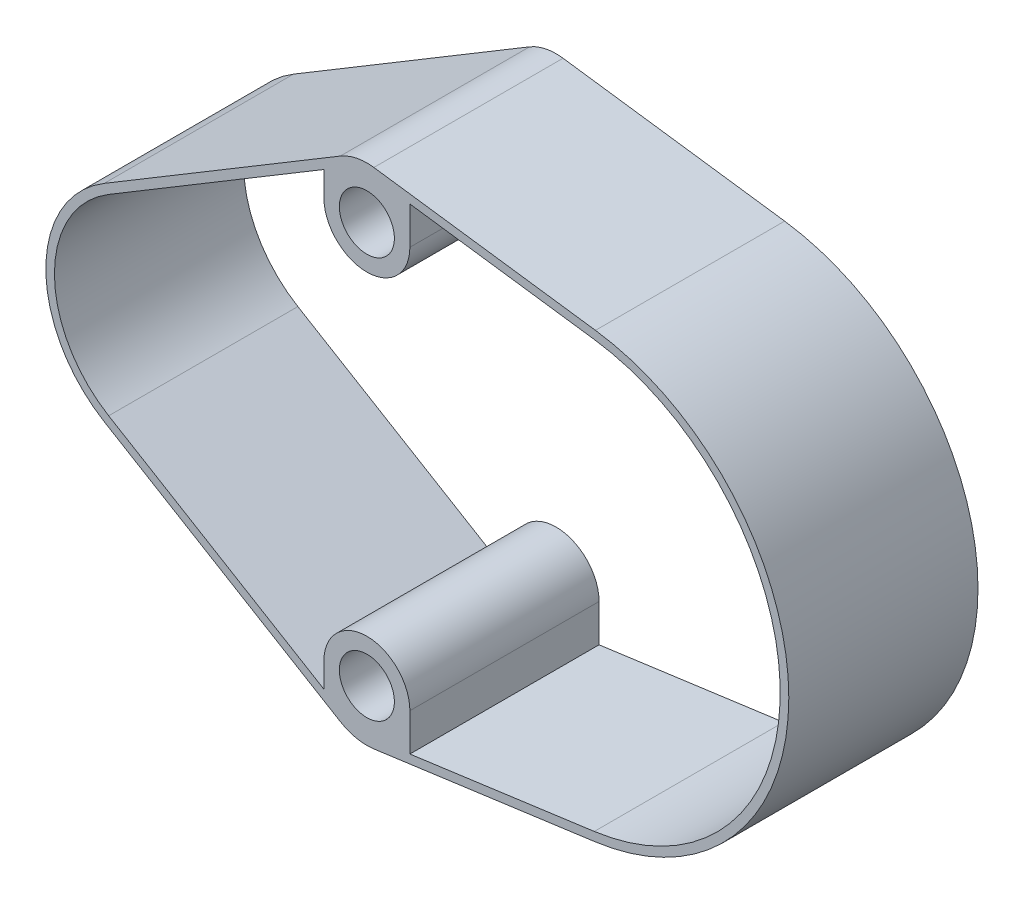
from build123d import *

# Parameters (mm, degrees)
SKETCH1_R           = 3
SKETCH1_R_2         = 4.5
SKETCH1_R_3         = 1.6
BOSS_EXTRUDE3_DEPTH = 1.6
SKETCH2_R           = 1.6
SKETCH2_R_2         = 3
SKETCH2_R_3         = 4.5
BOSS_EXTRUDE4_DEPTH = 1.5
SKETCH3_R           = 63.206562555
CUT_EXTRUDE1_DEPTH  = 1.6
SKETCH4_R           = 3
SKETCH4_R_2         = 1.6
BOSS_EXTRUDE5_DEPTH = 1.5
SKETCH5_R           = 1.6
BOSS_EXTRUDE6_DEPTH = 11
SKETCH6_R           = 49.514430464
CUT_EXTRUDE2_DEPTH  = 1.5


with BuildPart() as part:
    # Sketch1 → Boss-Extrude3 (new body)
    with BuildSketch(Plane.XY):
        with BuildLine():
            Line((12.073070054, 14.639688463), (24.958502044, 12.880515151))
            ThreePointArc((24.958502044, 12.880515151), (36.2, 0), (24.958502044, -12.880515151))
            Line((24.958502044, -12.880515151), (12.073070054, -14.639688463))
            ThreePointArc((12.073070054, -14.639688463), (11.870633815, -14.660360595), (11.66726189, -14.66726189))
            Line((11.66726189, -14.66726189), (0, -14.66726189))
            ThreePointArc((0, -14.66726189), (-0.888679088, -14.53261518), (-1.697586366, -14.140761542))
            Line((-1.697586366, -14.140761542), (-18.697586366, -2.473499652))
            ThreePointArc((-18.697586366, -2.473499652), (-19.891071988, -0.801063519), (-19.728500117, 1.247111507))
            Line((-19.728500117, 1.247111507), (-14.395762007, 12.914373397))
            ThreePointArc((-14.395762007, 12.914373397), (-13.288783625, 14.191279968), (-11.66726189, 14.66726189))
            Line((-11.66726189, 14.66726189), (11.66726189, 14.66726189))
            ThreePointArc((11.66726189, 14.66726189), (11.870633815, 14.660360595), (12.073070054, 14.639688463))
        make_face()
        Circle(SKETCH1_R, mode=Mode.SUBTRACT)
        with Locations((23.2, 0)):
            Circle(SKETCH1_R_2, mode=Mode.SUBTRACT)
        with Locations((8.6, 0)):
            Circle(SKETCH1_R, mode=Mode.SUBTRACT)
        with Locations((-17, 0)):
            Circle(SKETCH1_R_3, mode=Mode.SUBTRACT)
        with Locations((0, -11.66726189)):
            Circle(SKETCH1_R_3, mode=Mode.SUBTRACT)
        with Locations((11.66726189, -11.66726189)):
            Circle(SKETCH1_R_3, mode=Mode.SUBTRACT)
        with Locations((-11.66726189, 11.66726189)):
            Circle(SKETCH1_R_3, mode=Mode.SUBTRACT)
        with Locations((0, 11.66726189)):
            Circle(SKETCH1_R_3, mode=Mode.SUBTRACT)
        with Locations((11.66726189, 11.66726189)):
            Circle(SKETCH1_R_3, mode=Mode.SUBTRACT)
    extrude(amount=BOSS_EXTRUDE3_DEPTH)

    # Sketch2 → Boss-Extrude4 (add)
    with BuildSketch(Plane.XY.offset(1.6)):
        with BuildLine():
            Line((12.073070054, 14.639688463), (24.958502044, 12.880515151))
            ThreePointArc((24.958502044, 12.880515151), (36.2, 0), (24.958502044, -12.880515151))
            Line((24.958502044, -12.880515151), (12.073070054, -14.639688463))
            ThreePointArc((12.073070054, -14.639688463), (10.884137398, -14.56324463), (9.81871257, -14.030070687))
            Line((9.81871257, -14.030070687), (-3.080915533, -3.938014662))
            ThreePointArc((-3.080915533, -3.938014662), (-5, 0), (-3.080915533, 3.938014662))
            Line((-3.080915533, 3.938014662), (9.81871257, 14.030070687))
            ThreePointArc((9.81871257, 14.030070687), (10.884137398, 14.56324463), (12.073070054, 14.639688463))
        make_face()
        with Locations((11.66726189, 11.66726189)):
            Circle(SKETCH2_R, mode=Mode.SUBTRACT)
        Circle(SKETCH2_R_2, mode=Mode.SUBTRACT)
        with Locations((8.6, 0)):
            Circle(SKETCH2_R_2, mode=Mode.SUBTRACT)
        with Locations((23.2, 0)):
            Circle(SKETCH2_R_3, mode=Mode.SUBTRACT)
        with Locations((11.66726189, -11.66726189)):
            Circle(SKETCH2_R, mode=Mode.SUBTRACT)
    extrude(amount=BOSS_EXTRUDE4_DEPTH)

    # Sketch3 → Cut-Extrude1 (cut)
    with BuildSketch(Plane(origin=(0, 0, 0), x_dir=(-1, 0, 0), z_dir=(0, 0, -1))):
        Circle(SKETCH3_R)
    extrude(amount=-CUT_EXTRUDE1_DEPTH, mode=Mode.SUBTRACT)

    # Sketch4 → Boss-Extrude5 (add)
    with BuildSketch(Plane.XY.offset(3.1)):
        with BuildLine():
            Line((-3.602159399, 6.00203696), (10.12347929, 14.239563444))
            ThreePointArc((10.12347929, 14.239563444), (13.145208472, 14.277946455), (14.66726189, 11.66726189))
            Line((14.66726189, 11.66726189), (14.66726189, -11.66726189))
            ThreePointArc((14.66726189, -11.66726189), (13.145208472, -14.277946455), (10.12347929, -14.239563444))
            Line((10.12347929, -14.239563444), (-3.602159399, -6.00203696))
            ThreePointArc((-3.602159399, -6.00203696), (-7, 0), (-3.602159399, 6.00203696))
        make_face()
        Circle(SKETCH4_R, mode=Mode.SUBTRACT)
        with Locations((8.6, 0)):
            Circle(SKETCH4_R, mode=Mode.SUBTRACT)
        with Locations((11.66726189, 11.66726189)):
            Circle(SKETCH4_R_2, mode=Mode.SUBTRACT)
        with Locations((11.66726189, -11.66726189)):
            Circle(SKETCH4_R_2, mode=Mode.SUBTRACT)
    extrude(amount=-BOSS_EXTRUDE5_DEPTH)

    # Sketch5 → Boss-Extrude6 (add)
    with BuildSketch(Plane.XY.offset(3.1)):
        with BuildLine():
            Line((10.12347929, 14.239563444), (-3.602159399, 6.00203696))
            ThreePointArc((-3.602159399, 6.00203696), (-7, 0), (-3.602159399, -6.00203696))
            Line((-3.602159399, -6.00203696), (10.12347929, -14.239563444))
            ThreePointArc((10.12347929, -14.239563444), (11.064127193, -14.606007972), (12.073070054, -14.639688463))
            Line((12.073070054, -14.639688463), (24.958502044, -12.880515151))
            ThreePointArc((24.958502044, -12.880515151), (36.2, 0), (24.958502044, 12.880515151))
            Line((24.958502044, 12.880515151), (12.073070054, 14.639688463))
            ThreePointArc((12.073070054, 14.639688463), (11.064127193, 14.606007972), (10.12347929, 14.239563444))
        make_face()
        with Locations((11.66726189, -11.66726189)):
            Circle(SKETCH5_R, mode=Mode.SUBTRACT)
        with BuildLine():
            Line((-3.345341009, 5.573371264), (3.517564288, 9.692737701))
            Line((3.517564288, 9.692737701), (9.16726189, 13.083892566))
            Line((9.16726189, 13.083892566), (9.16726189, 11.66726189))
            ThreePointArc((9.16726189, 11.66726189), (11.66726189, 9.16726189), (14.16726189, 11.66726189))
            Line((14.16726189, 11.66726189), (14.16726189, 13.849142394))
            Line((14.16726189, 13.849142394), (18.333589211, 13.280337883))
            Line((18.333589211, 13.280337883), (24.89086735, 12.385110722))
            ThreePointArc((24.89086735, 12.385110722), (35.7, 0), (24.89086735, -12.385110722))
            Line((24.89086735, -12.385110722), (18.333589211, -13.280337883))
            Line((18.333589211, -13.280337883), (14.16726189, -13.849142394))
            Line((14.16726189, -13.849142394), (14.16726189, -11.66726189))
            ThreePointArc((14.16726189, -11.66726189), (11.66726189, -9.16726189), (9.16726189, -11.66726189))
            Line((9.16726189, -11.66726189), (9.16726189, -13.083892566))
            Line((9.16726189, -13.083892566), (3.517564288, -9.692737701))
            Line((3.517564288, -9.692737701), (-3.345341009, -5.573371264))
            ThreePointArc((-3.345341009, -5.573371264), (-6.500290279, 0), (-3.345341009, 5.573371264))
        make_face(mode=Mode.SUBTRACT)
        with Locations((11.66726189, 11.66726189)):
            Circle(SKETCH5_R, mode=Mode.SUBTRACT)
    extrude(amount=BOSS_EXTRUDE6_DEPTH)

    # Sketch6 → Cut-Extrude2 (cut)
    with BuildSketch(Plane(origin=(0, 0, 1.6), x_dir=(-1, 0, 0), z_dir=(0, 0, -1))):
        Circle(SKETCH6_R)
    extrude(amount=-CUT_EXTRUDE2_DEPTH, mode=Mode.SUBTRACT)


solid = part.part
